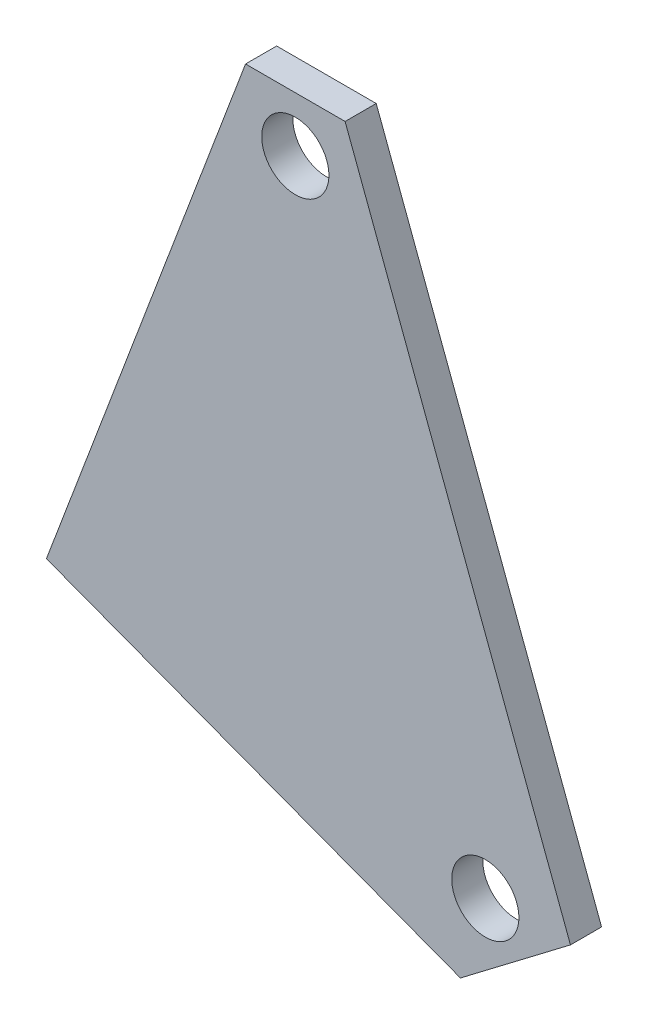
from build123d import *

# Parameters (mm, degrees)
SKETCH1_R           = 3.429
BOSS_EXTRUDE1_DEPTH = 3.175


with BuildPart() as part:
    # Sketch1 → Boss-Extrude1 (new body)
    with BuildSketch(Plane.XY.offset(117.785358826)):
        Polygon((54.178453288, 19.606929499), (42.949199141, 11.069173633), (0.699486381, 27.001944289), (21.019486381, 80.885489203), (31.179486381, 80.885489203), align=None)
        with Locations((45.489199141, 19.381944289)):
            Circle(SKETCH1_R, mode=Mode.SUBTRACT)
        with Locations((26.099486381, 75.297489203)):
            Circle(SKETCH1_R, mode=Mode.SUBTRACT)
    extrude(amount=BOSS_EXTRUDE1_DEPTH)


solid = part.part
